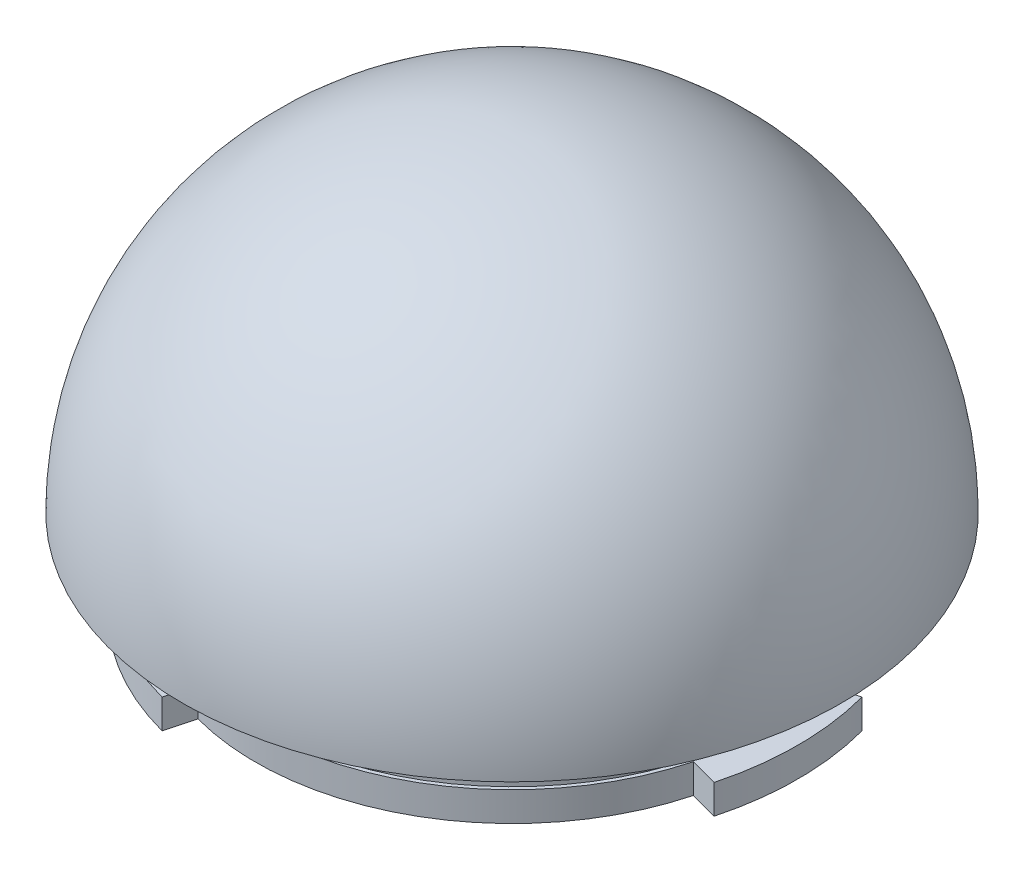
from build123d import *

# Parameters (mm, degrees)
REVOLVE1_ANGLE      = 180
SKETCH4_R           = 41.29501491
BOSS_EXTRUDE1_DEPTH = 7
SKETCH5_R           = 34.5
BOSS_EXTRUDE2_DEPTH = 12
SKETCH6_R           = 39
BOSS_EXTRUDE4_DEPTH = 4
SKETCH7_R           = 30
CUT_EXTRUDE1_DEPTH  = 24
CUT_EXTRUDE2_DEPTH  = 10


with BuildPart() as part:
    # Sketch1 → Revolve1 (revolve)
    with BuildSketch(Plane(origin=(0, 0, 0), x_dir=(1, 0, 0), z_dir=(0, 1, 0))):
        with BuildLine():
            Line((1.220496419, 44.983445716), (-1.220496419, -44.983445716))
            ThreePointArc((-1.220496419, -44.983445716), (44.983445716, -1.220496419), (1.220496419, 44.983445716))
        make_face()
    revolve(axis=Axis((1.220496419, 0, -44.983445716), (-0.027122143, 0, 0.999632127)), revolution_arc=REVOLVE1_ANGLE)

    # Sketch2 → Cut-Revolve1 (revolve, cut)
    with BuildSketch(Plane.XZ):
        with BuildLine():
            Line((39.984553657, 1.111516454), (-39.984553657, -1.111516454))
            ThreePointArc((-39.984553657, -1.111516454), (-1.111516454, 39.984553657), (39.984553657, 1.111516454))
        make_face()
    revolve(axis=Axis((39.984553657, 0, 1.111516454), (-0.999613841, 0, -0.027787911)), mode=Mode.SUBTRACT)

    # Sketch4 → Boss-Extrude1 (add)
    with BuildSketch(Plane.XZ):
        Circle(SKETCH4_R)
    extrude(amount=-BOSS_EXTRUDE1_DEPTH)

    # Sketch5 → Boss-Extrude2 (add)
    with BuildSketch(Plane.XZ):
        Circle(SKETCH5_R)
    extrude(amount=BOSS_EXTRUDE2_DEPTH)

    # Sketch6 → Boss-Extrude4 (add)
    with BuildSketch(Plane.XZ.offset(12)):
        Circle(SKETCH6_R)
    extrude(amount=-BOSS_EXTRUDE4_DEPTH)

    # Sketch7 → Cut-Extrude1 (cut)
    with BuildSketch(Plane.XZ.offset(12)):
        Circle(SKETCH7_R)
    extrude(amount=-CUT_EXTRUDE1_DEPTH, mode=Mode.SUBTRACT)

    # Sketch8 → Cut-Extrude2 (cut)
    with BuildSketch(Plane.XZ.offset(12)):
        with BuildLine():
            ThreePointArc((37.671107225, 10.093942759), (19.5, 33.774990748), (-10.093942759, 37.671107225))
            Line((-10.093942759, 37.671107225), (-9.058666579, 33.80740392))
            ThreePointArc((-9.058666579, 33.80740392), (17.5, 30.310889132), (33.80740392, 9.058666579))
            Line((33.80740392, 9.058666579), (37.671107225, 10.093942759))
        make_face()
        with BuildLine():
            ThreePointArc((-10.093942759, -37.671107225), (19.5, -33.774990748), (37.671107225, -10.093942759))
            Line((37.671107225, -10.093942759), (33.80740392, -9.058666579))
            ThreePointArc((33.80740392, -9.058666579), (17.5, -30.310889132), (-9.058666579, -33.80740392))
            Line((-9.058666579, -33.80740392), (-10.093942759, -37.671107225))
        make_face()
        with BuildLine():
            Line((-24.748737342, 24.748737342), (-27.577164466, 27.577164466))
            ThreePointArc((-27.577164466, 27.577164466), (-39, 0), (-27.577164466, -27.577164466))
            Line((-27.577164466, -27.577164466), (-24.748737342, -24.748737342))
            ThreePointArc((-24.748737342, -24.748737342), (-35, 0), (-24.748737342, 24.748737342))
        make_face()
    extrude(amount=-CUT_EXTRUDE2_DEPTH, mode=Mode.SUBTRACT)


solid = part.part
